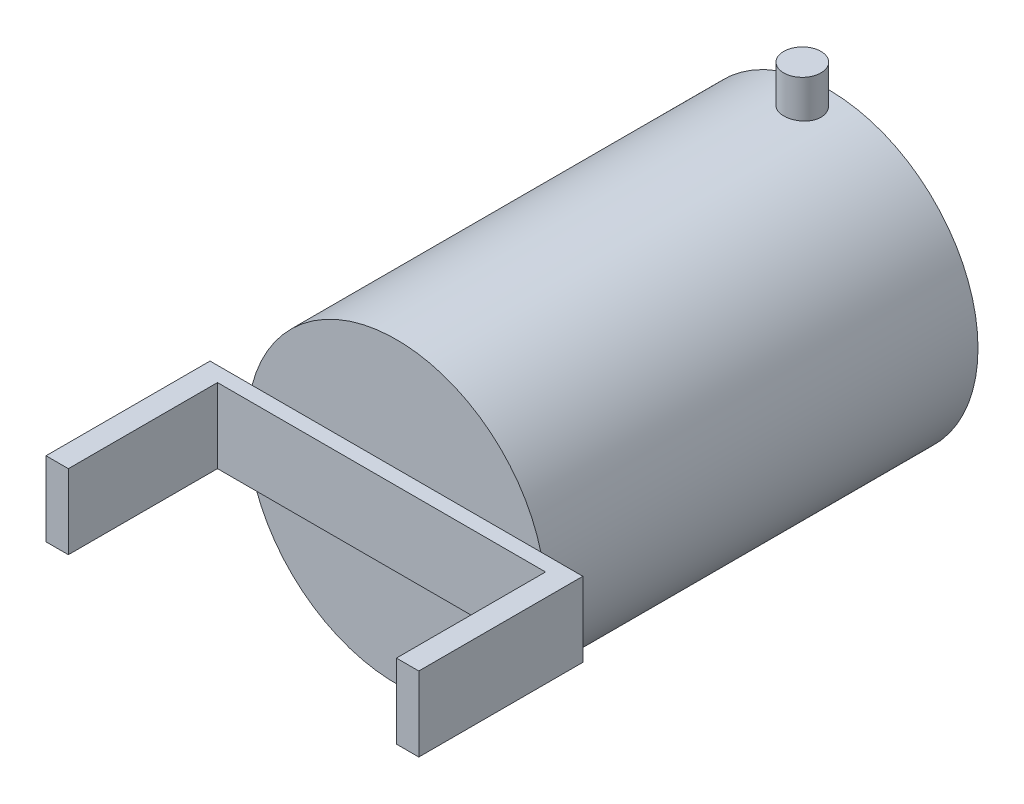
from build123d import *

# Parameters (mm, degrees)
SKETCH1_R           = 20
BOSS_EXTRUDE1_DEPTH = 58
SKETCH7_R           = 2.5
BOSS_EXTRUDE2_DEPTH = 25
SKETCH8_W           = 50
SKETCH8_H           = 10
BOSS_EXTRUDE3_DEPTH = 2
SKETCH9_W           = 3
SKETCH9_H           = 10
BOSS_EXTRUDE4_DEPTH = 20
SKETCH10_W          = 3
SKETCH10_H          = 10
BOSS_EXTRUDE5_DEPTH = 20


with BuildPart() as part:
    # Sketch1 → Boss-Extrude1 (new body)
    with BuildSketch(Plane.XY):
        Circle(SKETCH1_R)
    extrude(amount=BOSS_EXTRUDE1_DEPTH)

    # Sketch7 → Boss-Extrude2 (add)
    with BuildSketch(Plane(origin=(0, 0, 0), x_dir=(1, 0, 0), z_dir=(0, 1, 0))):
        with Locations((0, -3.561686207)):
            Circle(SKETCH7_R)
    boss_extrude2 = extrude(amount=BOSS_EXTRUDE2_DEPTH)

    # Sketch8 → Boss-Extrude3 (add)
    with BuildSketch(Plane.XY.offset(58)):
        Rectangle(SKETCH8_W, SKETCH8_H)
    extrude(amount=BOSS_EXTRUDE3_DEPTH)

    # Sketch9 → Boss-Extrude4 (add)
    with BuildSketch(Plane.XY.offset(60)):
        with Locations((-23.5, 0)):
            Rectangle(SKETCH9_W, SKETCH9_H)
    extrude(amount=BOSS_EXTRUDE4_DEPTH)

    # Sketch10 → Boss-Extrude5 (add)
    with BuildSketch(Plane.XY.offset(60)):
        with Locations((23.5, 0)):
            Rectangle(SKETCH10_W, SKETCH10_H)
    extrude(amount=BOSS_EXTRUDE5_DEPTH)

    # Mirror1: Boss-Extrude2 across plane
    add(boss_extrude2.mirror(Plane.ZX))


solid = part.part
